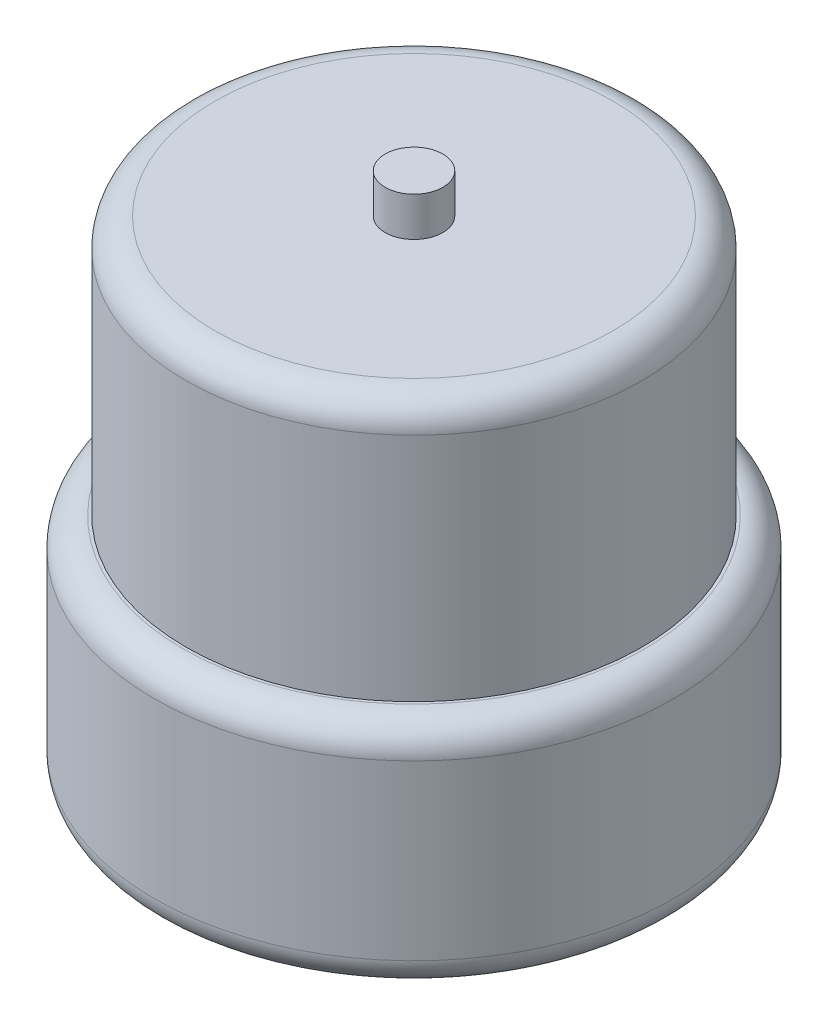
from build123d import *

# Parameters (mm, degrees)
SKETCH1_R           = 45
BOSS_EXTRUDE1_DEPTH = 40
SKETCH2_R           = 39.5
BOSS_EXTRUDE2_DEPTH = 45
SKETCH3_R           = 5
BOSS_EXTRUDE3_DEPTH = 6.8
FILLET1_R           = 5


with BuildPart() as part:
    # Sketch1 → Boss-Extrude1 (new body)
    with BuildSketch(Plane(origin=(0, 0, 0), x_dir=(1, 0, 0), z_dir=(0, 1, 0))):
        Circle(SKETCH1_R)
    extrude(amount=BOSS_EXTRUDE1_DEPTH)

    # Sketch2 → Boss-Extrude2 (add)
    with BuildSketch(Plane(origin=(0, 40, 0), x_dir=(1, 0, 0), z_dir=(0, 1, 0))):
        Circle(SKETCH2_R)
    extrude(amount=BOSS_EXTRUDE2_DEPTH)

    # Sketch3 → Boss-Extrude3 (add)
    with BuildSketch(Plane(origin=(0, 85, 0), x_dir=(1, 0, 0), z_dir=(0, 1, 0))):
        Circle(SKETCH3_R)
    extrude(amount=BOSS_EXTRUDE3_DEPTH)

    # Fillet1
    fillet1_edges = [part.edges().sort_by_distance(p)[0] for p in [
        (-45, 0, 0),
        (-45, 40, 0),
        (-39.5, 85, 0),
    ]]
    fillet(fillet1_edges, radius=FILLET1_R)


solid = part.part
